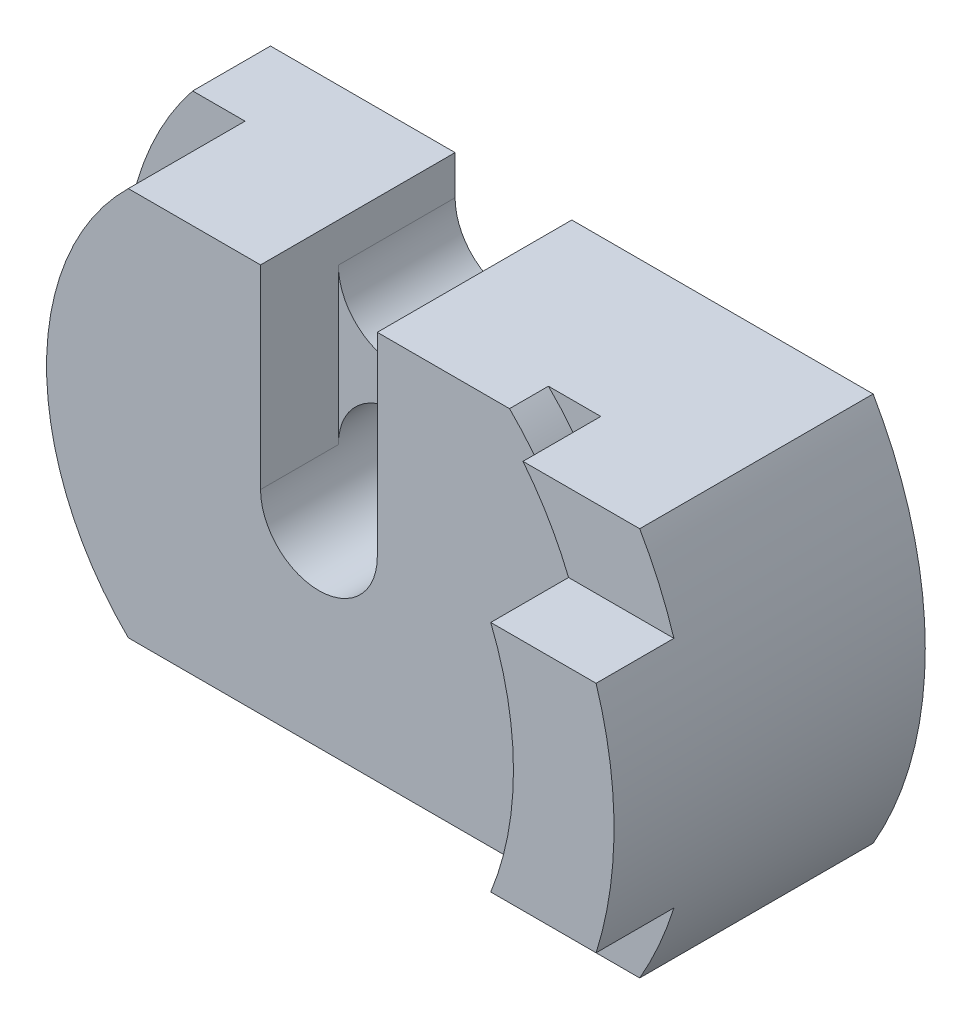
from build123d import *

# Parameters (mm, degrees)
SKETCH1_R           = 1.5
BOSS_EXTRUDE1_DEPTH = 2
SKETCH2_R           = 1.5
BOSS_EXTRUDE2_DEPTH = 3
BOSS_EXTRUDE3_DEPTH = 6
BOSS_EXTRUDE4_DEPTH = 2
CUT_EXTRUDE1_DEPTH  = 2
CUT_EXTRUDE2_DEPTH  = 4
BOSS_EXTRUDE5_DEPTH = 2


with BuildPart() as part:
    # Sketch1 → Boss-Extrude1 (new body)
    with BuildSketch(Plane.XY):
        with BuildLine():
            Line((-6.244997998, 5), (6.244997998, 5))
            ThreePointArc((6.244997998, 5), (8, 0), (6.244997998, -5))
            Line((6.244997998, -5), (-6.244997998, -5))
            ThreePointArc((-6.244997998, -5), (-8, 0), (-6.244997998, 5))
        make_face()
        Circle(SKETCH1_R, mode=Mode.SUBTRACT)
    extrude(amount=BOSS_EXTRUDE1_DEPTH)

    # Sketch2 → Boss-Extrude2 (add)
    with BuildSketch(Plane.XY.offset(2)):
        with BuildLine():
            Line((-4.898979486, -5), (4.898979486, -5))
            ThreePointArc((4.898979486, -5), (7, 0), (4.898979486, 5))
            Line((4.898979486, 5), (-4.898979486, 5))
            ThreePointArc((-4.898979486, 5), (-7, 0), (-4.898979486, -5))
        make_face()
        Circle(SKETCH2_R, mode=Mode.SUBTRACT)
    extrude(amount=BOSS_EXTRUDE2_DEPTH)

    # Sketch3 → Boss-Extrude3 (add)
    with BuildSketch(Plane(origin=(0, 0, 0), x_dir=(-1, 0, 0), z_dir=(0, 0, -1))):
        with BuildLine():
            Line((-6.244997998, -5), (-9.244997998, -5))
            ThreePointArc((-9.244997998, -5), (-10.584743961, 0), (-9.244997998, 5))
            Line((-9.244997998, 5), (-6.244997998, 5))
            ThreePointArc((-6.244997998, 5), (-8, 0), (-6.244997998, -5))
        make_face()
    extrude(amount=-BOSS_EXTRUDE3_DEPTH)

    # Sketch4 → Boss-Extrude4 (add)
    with BuildSketch(Plane.XY.offset(6)):
        with BuildLine():
            Line((7.416198487, 3), (10.124135975, 3))
            ThreePointArc((10.124135975, 3), (10.584743961, 0), (10.124135975, -3))
            Line((10.124135975, -3), (7.416198487, -3))
            ThreePointArc((7.416198487, -3), (8, 0), (7.416198487, 3))
        make_face()
    extrude(amount=BOSS_EXTRUDE4_DEPTH)

    # Sketch5 → Cut-Extrude1 (cut)
    with BuildSketch(Plane.XY.offset(5)):
        with BuildLine():
            Line((-1.5, 5), (-1.5, 0))
            ThreePointArc((-1.5, 0), (-4.1e-08, -1.5), (1.5, -8.1e-08))
            Line((1.5, -8.1e-08), (1.5, 5))
            Line((1.5, 5), (-1.5, 5))
        make_face()
    extrude(amount=-CUT_EXTRUDE1_DEPTH, mode=Mode.SUBTRACT)

    # Sketch6 → Cut-Extrude2 (cut)
    with BuildSketch(Plane.XY.offset(3)):
        with BuildLine():
            Line((-1.5, 5), (1.5, 5))
            Line((1.5, 5), (1.5, 3.995198361))
            ThreePointArc((1.5, 3.995198361), (0, 2.495198361), (-1.5, 3.995198361))
            Line((-1.5, 3.995198361), (-1.5, 5))
        make_face()
    extrude(amount=-CUT_EXTRUDE2_DEPTH, mode=Mode.SUBTRACT)

    # Sketch7 → Boss-Extrude5 (add)
    with BuildSketch(Plane.XY.offset(2)):
        with BuildLine():
            Line((4.898979486, -5), (6.244997998, -5))
            ThreePointArc((6.244997998, -5), (8, 0), (6.244997998, 5))
            Line((6.244997998, 5), (4.898979486, 5))
            ThreePointArc((4.898979486, 5), (7, 0), (4.898979486, -5))
        make_face()
    extrude(amount=BOSS_EXTRUDE5_DEPTH)


solid = part.part
